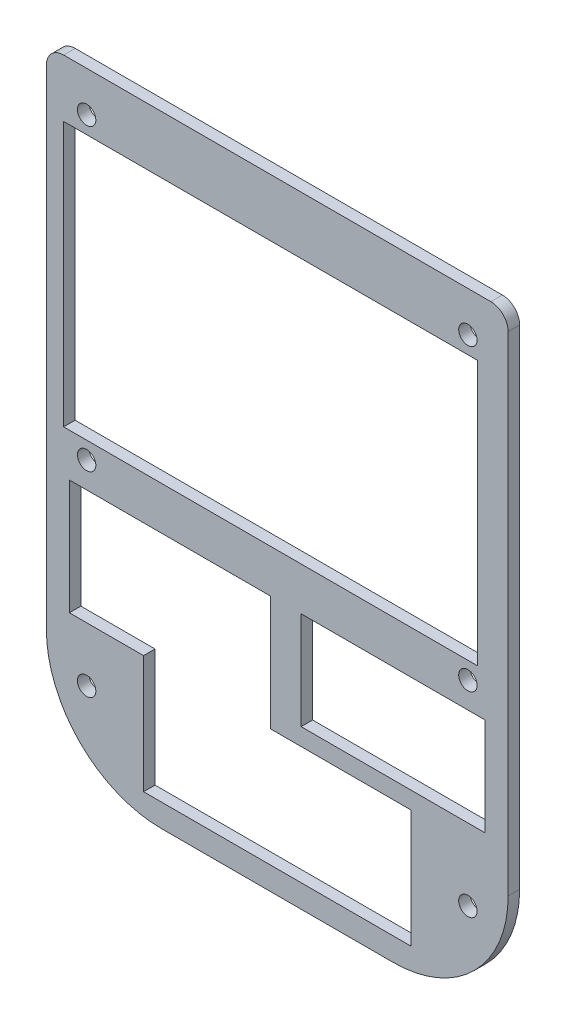
from build123d import *

# Parameters (mm, degrees)
SKETCH1_W                      = 80.3
SKETCH1_H                      = 66
BOSS_EXTRUDE1_DEPTH            = 2
F_3_2_3_2_DIAMETER_HOLE1_D     = 3.2
FILLET1_R                      = 3
SKETCH4_W                      = 80.3
SKETCH4_H                      = 2
BOSS_EXTRUDE2_DEPTH            = 42
FILLET2_R                      = 20
F_3_2_3_2_DIAMETER_HOLE2_D     = 3.2
F_3_2_3_2_DIAMETER_HOLE2_DEPTH = 60
F_3_2_3_2_DIAMETER_HOLE2_TIP   = 0.96137699
SKETCH7_W                      = 72
SKETCH7_H                      = 46
CUT_EXTRUDE1_DEPTH             = 3
SKETCH10_W                     = 35
SKETCH10_H                     = 20
SKETCH10_W_2                   = 32
SKETCH10_H_2                   = 17
CUT_EXTRUDE3_DEPTH             = 3


with BuildPart() as part:
    # Sketch1 → Boss-Extrude1 (new body)
    with BuildSketch(Plane.XY):
        with Locations((40.15, 33)):
            Rectangle(SKETCH1_W, SKETCH1_H)
    extrude(amount=BOSS_EXTRUDE1_DEPTH)

    # Ø3.2 (3.2) Diameter Hole1 (through all)
    with Locations(Plane.XY.offset(2)):
        with Locations((7, 59), (73.3, 59), (73.3, 7), (7, 7)):
            Hole(F_3_2_3_2_DIAMETER_HOLE1_D / 2)

    # Fillet1
    fillet1_edges = [part.edges().sort_by_distance(p)[0] for p in [
        (0, 66, 1),
        (80.3, 66, 1),
    ]]
    fillet(fillet1_edges, radius=FILLET1_R)

    # Sketch4 → Boss-Extrude2 (add)
    with BuildSketch(Plane.XZ):
        with Locations((40.15, 1)):
            Rectangle(SKETCH4_W, SKETCH4_H)
    extrude(amount=BOSS_EXTRUDE2_DEPTH)

    # Fillet2
    fillet2_edges = [part.edges().sort_by_distance(p)[0] for p in [
        (0, -42, 1),
        (80.3, -42, 1),
    ]]
    fillet(fillet2_edges, radius=FILLET2_R)

    # Ø3.2 (3.2) Diameter Hole2
    with Locations(Plane.XY.offset(2)):
        with Locations((7, -27), (73.3, -27)):
            Hole(F_3_2_3_2_DIAMETER_HOLE2_D / 2, depth=F_3_2_3_2_DIAMETER_HOLE2_DEPTH)
            with Locations((0, 0, -(F_3_2_3_2_DIAMETER_HOLE2_DEPTH + F_3_2_3_2_DIAMETER_HOLE2_TIP / 2))):  # 118° drill point
                Cone(0, F_3_2_3_2_DIAMETER_HOLE2_D / 2, F_3_2_3_2_DIAMETER_HOLE2_TIP, mode=Mode.SUBTRACT)

    # Sketch7 → Cut-Extrude1 (cut, through all)
    with BuildSketch(Plane.XY.offset(2)):
        with Locations((39, 33)):
            Rectangle(SKETCH7_W, SKETCH7_H)
    extrude(amount=-CUT_EXTRUDE1_DEPTH, mode=Mode.SUBTRACT)

    # Sketch10 → Cut-Extrude3 (cut, through all)
    with BuildSketch(Plane.XY.offset(2)):
        with Locations((21.5, -7.5)):
            Rectangle(SKETCH10_W, SKETCH10_H)
        Polygon((63.4, -17.5), (39, -17.5), (16.9, -17.5), (16.9, -38), (63.4, -38), align=None)
        with Locations((60.3, -6)):
            Rectangle(SKETCH10_W_2, SKETCH10_H_2)
    extrude(amount=-CUT_EXTRUDE3_DEPTH, mode=Mode.SUBTRACT)


solid = part.part
